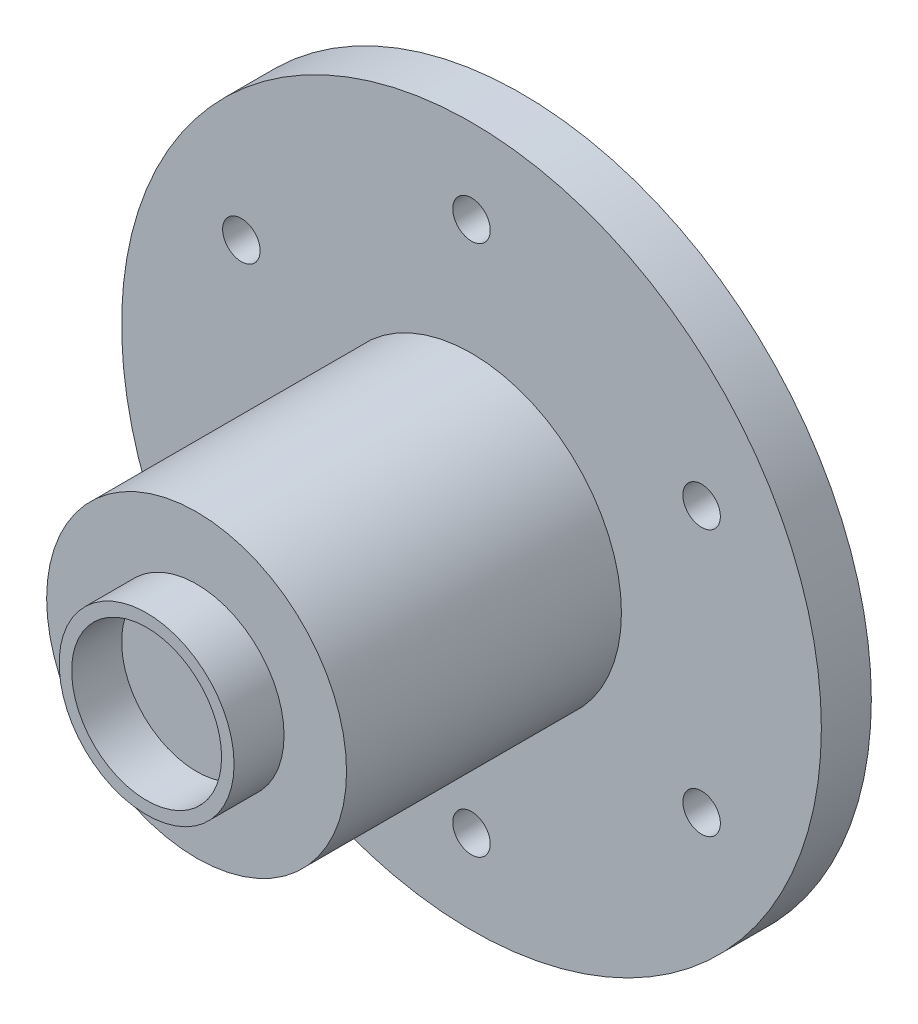
from build123d import *

# Parameters (mm, degrees)
SKETCH_1_R               = 28
EXTRUDE_1_DEPTH          = 4
SKETCH_2_R               = 12
EXTRUDE_2_DEPTH          = 22
SKETCH_3_R               = 5
CUT_EXTRUDE_1_DEPTH      = 60
SKETCH_4_R               = 1.5
CUT_EXTRUDE_2_DEPTH      = 7
PATTERN_CIRCULAR_1_COUNT = 6
SKETCH_5_R               = 1.5
CUT_EXTRUDE_3_DEPTH      = 15
SKETCH_7_R               = 7
EXTRUDE_4_DEPTH          = 10
SKETCH_8_R               = 6
CUT_EXTRUDE_4_DEPTH      = 4


with BuildPart() as part:
    # 草图1 → 凸台-拉伸1 (new body)
    with BuildSketch(Plane.XY):
        Circle(SKETCH_1_R)
    extrude(amount=EXTRUDE_1_DEPTH)

    # 草图2 → 凸台-拉伸2 (add)
    with BuildSketch(Plane.XY.offset(4)):
        Circle(SKETCH_2_R)
    extrude(amount=EXTRUDE_2_DEPTH)

    # 草图3 → 切除-拉伸1 (cut)
    with BuildSketch(Plane.XY.offset(26)):
        Circle(SKETCH_3_R)
    extrude(amount=-CUT_EXTRUDE_1_DEPTH, mode=Mode.SUBTRACT)

    # 草图4 → 切除-拉伸2 (cut)
    with BuildSketch(Plane(origin=(0, 0, 0), x_dir=(-1, 0, 0), z_dir=(0, 0, -1))):
        with Locations((0, 21.265645264)):
            Circle(SKETCH_4_R)
    cut_extrude_2 = extrude(amount=-CUT_EXTRUDE_2_DEPTH, mode=Mode.SUBTRACT)

    # 阵列(圆周)1: 切除-拉伸2 ×6 about axis
    pattern_circular_1_axis = Axis((0, 0, -1.3), (0, 0, 1))
    for i in range(1, PATTERN_CIRCULAR_1_COUNT):
        add(cut_extrude_2.rotate(pattern_circular_1_axis, i * 360 / PATTERN_CIRCULAR_1_COUNT), mode=Mode.SUBTRACT)

    # 草图5 → 切除-拉伸3 (cut)
    with BuildSketch(Plane(origin=(0, 0, 0), x_dir=(1, 0, 0), z_dir=(0, 1, 0))):
        with Locations((0, -16.223306721)):
            Circle(SKETCH_5_R)
    extrude(amount=-CUT_EXTRUDE_3_DEPTH, mode=Mode.SUBTRACT)

    # 草图7 → 凸台-拉伸4 (add)
    with BuildSketch(Plane.XY.offset(20)):
        Circle(SKETCH_7_R)
    extrude(amount=EXTRUDE_4_DEPTH)

    # 草图8 → 切除-拉伸4 (cut)
    with BuildSketch(Plane.XY.offset(30)):
        Circle(SKETCH_8_R)
    extrude(amount=-CUT_EXTRUDE_4_DEPTH, mode=Mode.SUBTRACT)


solid = part.part
